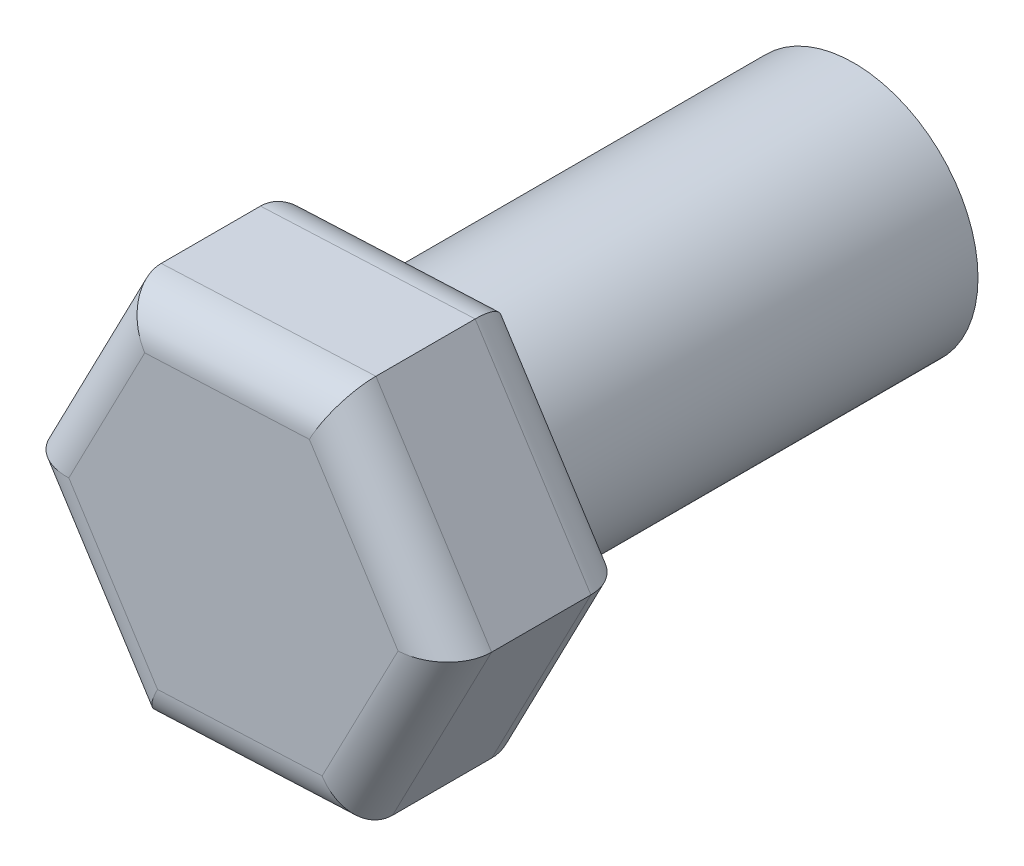
from build123d import *

# Parameters (mm, degrees)
SKETCH1_R           = 2
BOSS_EXTRUDE1_DEPTH = 7
BOSS_EXTRUDE2_DEPTH = 3
FILLET1_R           = 0.7


with BuildPart() as part:
    # Sketch1 → Boss-Extrude1 (new body)
    with BuildSketch(Plane.XY):
        Circle(SKETCH1_R)
    extrude(amount=BOSS_EXTRUDE1_DEPTH)

    # Sketch2 → Boss-Extrude2 (add)
    with BuildSketch(Plane.XY.offset(7)):
        Polygon((-1.595912417, -3.074583477), (1.864711189, -2.919392434), (3.460623606, 0.155191044), (1.595912417, 3.074583477), (-1.864711189, 2.919392434), (-3.460623606, -0.155191044), align=None)
    extrude(amount=BOSS_EXTRUDE2_DEPTH)

    # Fillet1
    fillet1_edges = [part.edges().sort_by_distance(p)[0] for p in [
        (2.528268011, 1.614887261, 7),
        (-0.134399386, 2.996987955, 7),
        (-2.662667397, 1.382100695, 7),
        (-2.528268011, -1.614887261, 7),
        (0.134399386, -2.996987955, 7),
        (2.662667397, -1.382100695, 7),
        (2.528268011, 1.614887261, 10),
        (-0.134399386, 2.996987955, 10),
        (-2.662667397, 1.382100695, 10),
        (-2.528268011, -1.614887261, 10),
        (0.134399386, -2.996987955, 10),
        (2.662667397, -1.382100695, 10),
    ]]
    fillet(fillet1_edges, radius=FILLET1_R)


solid = part.part
